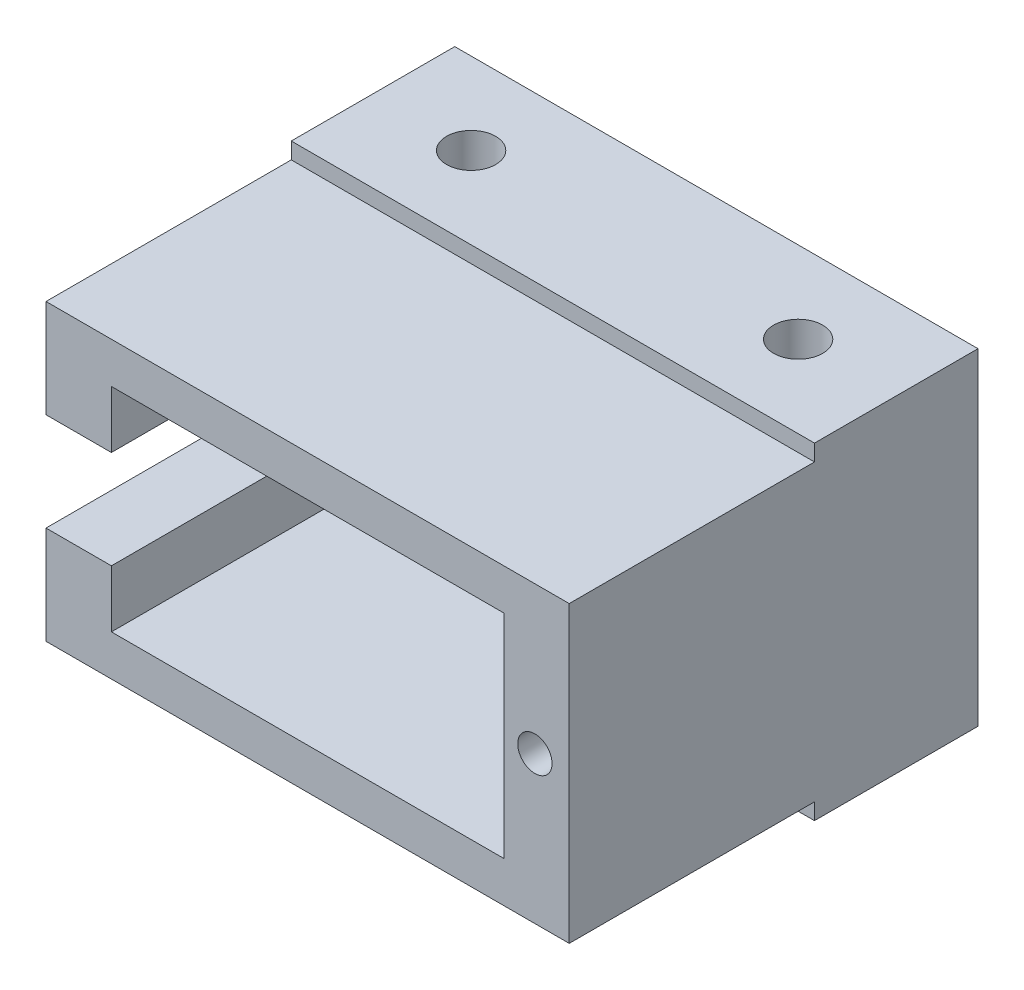
from build123d import *

# Parameters (mm, degrees)
ESQUISSE15_W             = 32
ESQUISSE15_H             = 20
BOSS_EXTRU_1_DEPTH       = 10
ESQUISSE16_W             = 32
ESQUISSE16_H             = 18
ESQUISSE16_W_2           = 24
ESQUISSE16_H_2           = 13
BOSS_EXTRU_2_DEPTH       = 15
ESQUISSE17_W             = 25
ESQUISSE17_H             = 6
ENL_V_MAT_EXTRU_8_DEPTH  = 4
ESQUISSE19_R             = 1.05
ENL_V_MAT_EXTRU_10_DEPTH = 6
ENL_V_MAT_EXTRU_11_REACH = 22
ESQUISSE20_R             = 1.5


with BuildPart() as part:
    # Esquisse15 → Boss.-Extru.1 (new body)
    with BuildSketch(Plane.XY):
        Rectangle(ESQUISSE15_W, ESQUISSE15_H)
    extrude(amount=BOSS_EXTRU_1_DEPTH)

    # Esquisse16 → Boss.-Extru.2 (add)
    with BuildSketch(Plane.XY.offset(10)):
        Rectangle(ESQUISSE16_W, ESQUISSE16_H)
        Rectangle(ESQUISSE16_W_2, ESQUISSE16_H_2, mode=Mode.SUBTRACT)
    extrude(amount=BOSS_EXTRU_2_DEPTH)

    # Esquisse17 → Enlèv. mat.-Extru.8 (cut)
    with BuildSketch(Plane.ZY.offset(16)):
        with Locations((12.5, 0)):
            Rectangle(ESQUISSE17_W, ESQUISSE17_H)
    extrude(amount=-ENL_V_MAT_EXTRU_8_DEPTH, mode=Mode.SUBTRACT)

    # Esquisse19 → Enlèv. mat.-Extru.10 (cut)
    with BuildSketch(Plane.XY.offset(25)):
        with Locations((13.9, 0)):
            Circle(ESQUISSE19_R)
    extrude(amount=-ENL_V_MAT_EXTRU_10_DEPTH, mode=Mode.SUBTRACT)

    # Esquisse20 → Enlèv. mat.-Extru.11 (cut, up to next)
    with BuildSketch(Plane(origin=(0, 10, 0), x_dir=(1, 0, 0), z_dir=(0, 1, 0)), mode=Mode.PRIVATE) as enl_v_mat_extru_11_sk1:
        with Locations((-10, -5)):
            Circle(ESQUISSE20_R)
    enl_v_mat_extru_11_tool1 = extrude(enl_v_mat_extru_11_sk1.sketch, amount=-ENL_V_MAT_EXTRU_11_REACH, mode=Mode.PRIVATE) & part.part
    add(enl_v_mat_extru_11_tool1.solids().sort_by_distance((-10, 10, 5))[0], mode=Mode.SUBTRACT)
    # Esquisse20 → Enlèv. mat.-Extru.11 (cut, up to next)
    with BuildSketch(Plane(origin=(0, 10, 0), x_dir=(1, 0, 0), z_dir=(0, 1, 0)), mode=Mode.PRIVATE) as enl_v_mat_extru_11_sk2:
        with Locations((10, -5)):
            Circle(ESQUISSE20_R)
    enl_v_mat_extru_11_tool2 = extrude(enl_v_mat_extru_11_sk2.sketch, amount=-ENL_V_MAT_EXTRU_11_REACH, mode=Mode.PRIVATE) & part.part
    add(enl_v_mat_extru_11_tool2.solids().sort_by_distance((10, 10, 5))[0], mode=Mode.SUBTRACT)


solid = part.part
